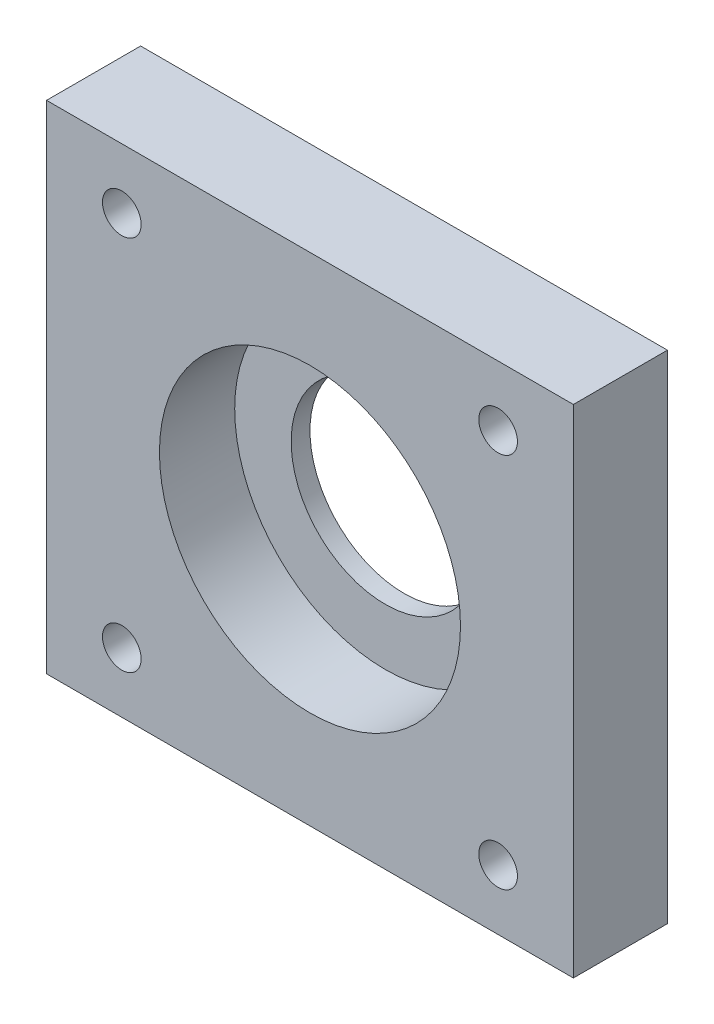
from build123d import *

# Parameters (mm, degrees)
SKETCH1_W           = 88.9
SKETCH1_H           = 83.82
BOSS_EXTRUDE1_DEPTH = 15.875
SKETCH2_R           = 3.2639
SKETCH2_R_2         = 15.875
CUT_EXTRUDE1_DEPTH  = 16.875
SKETCH3_R           = 25.4
CUT_EXTRUDE2_DEPTH  = 12.7


with BuildPart() as part:
    # Sketch1 → Boss-Extrude1 (new body)
    with BuildSketch(Plane.XY):
        Rectangle(SKETCH1_W, SKETCH1_H)
    extrude(amount=BOSS_EXTRUDE1_DEPTH)

    # Sketch2 → Cut-Extrude1 (cut, through all)
    with BuildSketch(Plane.XY.offset(15.875)):
        with Locations((-31.75, 31.75)):
            Circle(SKETCH2_R)
        with Locations((31.75, 31.75)):
            Circle(SKETCH2_R)
        with Locations((31.75, -31.75)):
            Circle(SKETCH2_R)
        with Locations((-31.75, -31.75)):
            Circle(SKETCH2_R)
        Circle(SKETCH2_R_2)
    extrude(amount=-CUT_EXTRUDE1_DEPTH, mode=Mode.SUBTRACT)

    # Sketch3 → Cut-Extrude2 (cut)
    with BuildSketch(Plane.XY.offset(15.875)):
        Circle(SKETCH3_R)
    extrude(amount=-CUT_EXTRUDE2_DEPTH, mode=Mode.SUBTRACT)


solid = part.part
